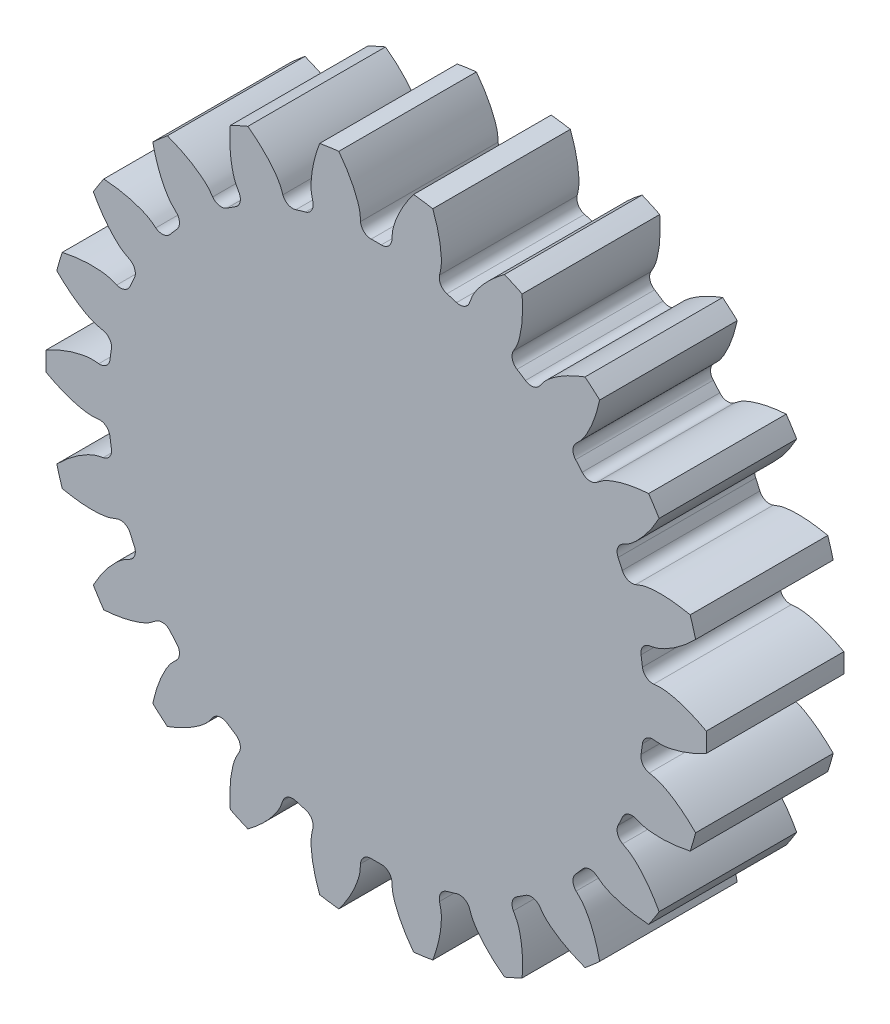
from build123d import *

# Parameters (mm, degrees)
SKETCH_1_R          = 12
LASHENA_DEPTH       = 5
CUT_EXTRUDEA_DEPTH  = 10
WWW_KYTOOL_CN_COUNT = 22


with BuildPart() as part:
    # 草图1 → LaShenA (new body)
    with BuildSketch(Plane.XY):
        Circle(SKETCH_1_R)
    extrude(amount=LASHENA_DEPTH)

    # SketchA → Cut-ExtrudeA (cut)
    with BuildSketch(Plane.XY.offset(5)):
        with BuildLine():
            ThreePointArc((0.182879362, 9.748284728), (0, 9.75), (-0.182879362, 9.748284728))
            ThreePointArc((-0.182879362, 9.748284728), (-0.448060073, 9.849275956), (-0.569345731, 10.105810216))
            add(Edge.make_bspline(
                [(-0.569345731, 10.105810216), (-0.573591107, 10.177680095), (-0.577643596, 10.279301189), (-0.593745042, 10.393872889), (-0.605991459, 10.452320563), (-0.616818624, 10.498614976), (-0.630770308, 10.551669694), (-0.648153589, 10.611362458), (-0.669349266, 10.677537989), (-0.694706721, 10.750032499), (-0.724577307, 10.82866601), (-0.759303081, 10.913245071), (-0.799219658, 11.003562214), (-0.84465469, 11.099396443), (-0.895927694, 11.200513431), (-0.953349478, 11.306665825), (-1.017221714, 11.417593537), (-1.08783646, 11.533024063), (-1.165475733, 11.652672813), (-1.250411053, 11.776243453), (-1.342903064, 11.903428265), (-1.443200981, 12.03390853), (-1.590730176, 12.21562271), (-1.709283, 12.3500743), (-1.792204576, 12.439417704)],
                knots=[0.122554338, 0.122554338, 0.122554338, 0.122554338, 0.19270508, 0.222547384, 0.235684065, 0.251209233, 0.269122888, 0.289425031, 0.31211566, 0.337194777, 0.364662381, 0.394518473, 0.426763051, 0.461396117, 0.49841767, 0.537827711, 0.579626238, 0.623813253, 0.670388755, 0.719352744, 0.770705221, 0.824446185, 0.880575636, 1, 1, 1, 1], degree=3))
            ThreePointArc((-1.792204576, 12.439417704), (0, 12.567860202), (1.792204576, 12.439417704))
            add(Edge.make_bspline(
                [(0.569345731, 10.105810216), (0.573591107, 10.177680095), (0.577643596, 10.279301189), (0.593745042, 10.393872889), (0.605991459, 10.452320563), (0.616818624, 10.498614976), (0.630770308, 10.551669694), (0.648153589, 10.611362458), (0.669349266, 10.677537989), (0.694706721, 10.750032499), (0.724577307, 10.82866601), (0.759303081, 10.913245071), (0.799219658, 11.003562214), (0.84465469, 11.099396443), (0.895927694, 11.200513431), (0.953349478, 11.306665825), (1.017221714, 11.417593537), (1.08783646, 11.533024063), (1.165475733, 11.652672813), (1.250411053, 11.776243453), (1.342903064, 11.903428265), (1.443200981, 12.03390853), (1.590730176, 12.21562271), (1.709283, 12.3500743), (1.792204576, 12.439417704)],
                knots=[0.122554338, 0.122554338, 0.122554338, 0.122554338, 0.19270508, 0.222547384, 0.235684065, 0.251209233, 0.269122888, 0.289425031, 0.31211566, 0.337194777, 0.364662381, 0.394518473, 0.426763051, 0.461396117, 0.49841767, 0.537827711, 0.579626238, 0.623813253, 0.670388755, 0.719352744, 0.770705221, 0.824446185, 0.880575636, 1, 1, 1, 1], degree=3))
            ThreePointArc((0.569345731, 10.105810216), (0.448060073, 9.849275956), (0.182879362, 9.748284728))
        make_face()
    cut_extrudea = extrude(amount=-CUT_EXTRUDEA_DEPTH, mode=Mode.SUBTRACT)

    # www.KYTool.cn: Cut-ExtrudeA ×22 about axis
    www_kytool_cn_axis = Axis((0, 0, -88.99), (0, 0, 1))
    for i in range(1, WWW_KYTOOL_CN_COUNT):
        add(cut_extrudea.rotate(www_kytool_cn_axis, i * 360 / WWW_KYTOOL_CN_COUNT), mode=Mode.SUBTRACT)


solid = part.part
